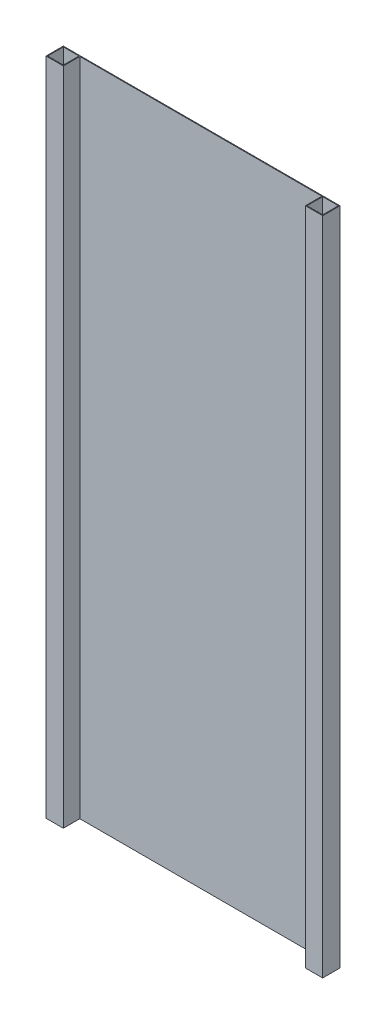
from build123d import *

# Parameters (mm, degrees)
SKETCH_2_W          = 308
SKETCH_2_H          = 840
EXTRUDE_1_DEPTH     = 1
SKETCH_2_3_W        = 22
SKETCH_2_3_H        = 840
EXTRUDE_2_DEPTH     = 22
SKETCH_4_W          = 20
SKETCH_4_H          = 20
CUT_EXTRUDE_1_DEPTH = 840
SKETCH_4_3_W        = 20
SKETCH_4_3_H        = 20
CUT_EXTRUDE_2_DEPTH = 840


with BuildPart() as part:
    # 스케치2 → 보스-돌출1 (new body)
    with BuildSketch(Plane.XY):
        with Locations((-176, 420)):
            Rectangle(SKETCH_2_W, SKETCH_2_H)
    extrude(amount=EXTRUDE_1_DEPTH)

    # 스케치2<3> → 보스-돌출2 (add)
    with BuildSketch(Plane.XY):
        with Locations((-11, 420)):
            Rectangle(SKETCH_2_3_W, SKETCH_2_3_H)
        with Locations((-341, 420)):
            Rectangle(SKETCH_2_3_W, SKETCH_2_3_H)
    extrude(amount=EXTRUDE_2_DEPTH)

    # 스케치4 → 컷-돌출1 (cut)
    with BuildSketch(Plane(origin=(0, 840, 0), x_dir=(1, 0, 0), z_dir=(0, 1, 0))):
        with Locations((-11, -11)):
            Rectangle(SKETCH_4_W, SKETCH_4_H)
    extrude(amount=-CUT_EXTRUDE_1_DEPTH, mode=Mode.SUBTRACT)

    # 스케치4<3> → 컷-돌출2 (cut)
    with BuildSketch(Plane(origin=(0, 840, 0), x_dir=(1, 0, 0), z_dir=(0, 1, 0))):
        with Locations((-341, -11)):
            Rectangle(SKETCH_4_3_W, SKETCH_4_3_H)
    extrude(amount=-CUT_EXTRUDE_2_DEPTH, mode=Mode.SUBTRACT)


solid = part.part
